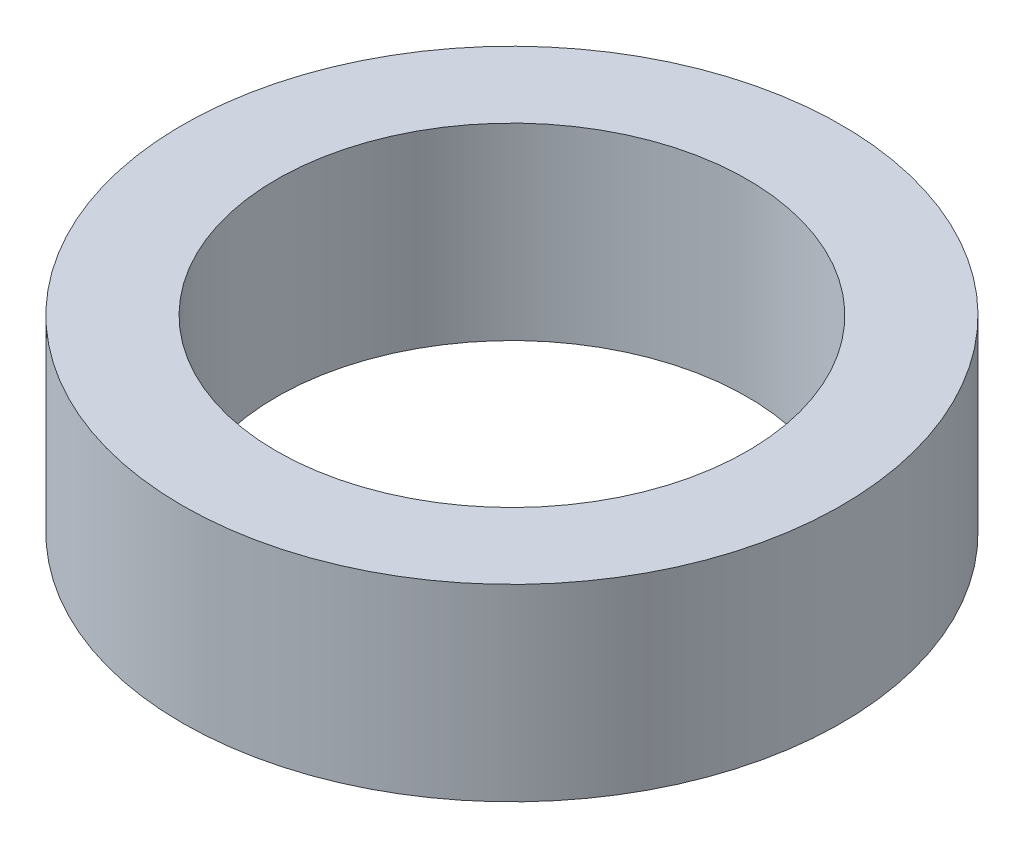
from build123d import *

# Parameters (mm, degrees)
SKETCH1_R           = 22.225
SKETCH1_R_2         = 15.875
BOSS_EXTRUDE1_DEPTH = 12.7


with BuildPart() as part:
    # Sketch1 → Boss-Extrude1 (new body)
    with BuildSketch(Plane(origin=(0, 0, 0), x_dir=(1, 0, 0), z_dir=(0, 1, 0))):
        Circle(SKETCH1_R)
        Circle(SKETCH1_R_2, mode=Mode.SUBTRACT)
    extrude(amount=BOSS_EXTRUDE1_DEPTH)


solid = part.part
